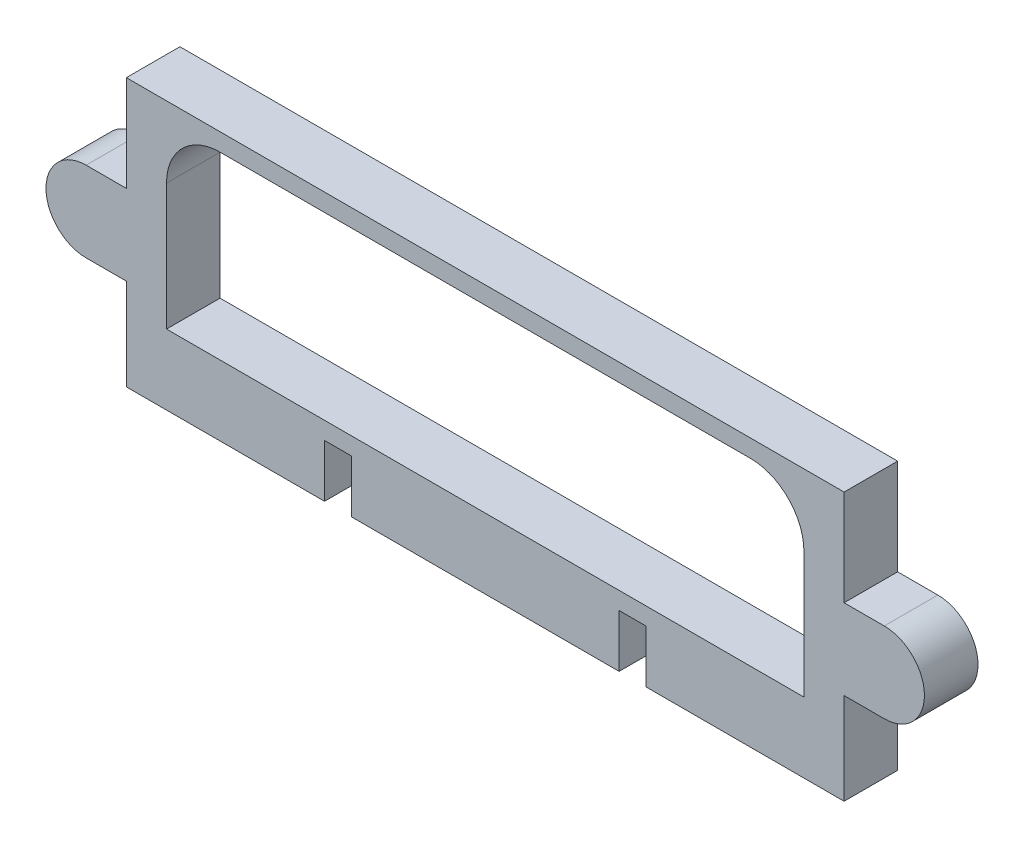
from build123d import *

# Parameters (mm, degrees)
SALIENTE_EXTRUIR1_DEPTH = 10


with BuildPart() as part:
    # Croquis1 → Saliente-Extruir1 (new body)
    with BuildSketch(Plane.XY):
        with BuildLine():
            Line((-25, 9.844348503), (-25, 0))
            Line((-25, 0), (25, 0))
            Line((25, 0), (25, 9.844348503))
            Line((25, 9.844348503), (30, 9.844348503))
            Line((30, 9.844348503), (30, 0))
            Line((30, 0), (67, 0))
            Line((67, 0), (67, 17.097567982))
            Line((67, 17.097567982), (74.5, 17.097567982))
            ThreePointArc((74.5, 17.097567982), (82, 24.597567982), (74.5, 32.097567982))
            Line((74.5, 32.097567982), (67, 32.097567982))
            Line((67, 32.097567982), (67, 50))
            Line((67, 50), (-67, 50))
            Line((-67, 50), (-67, 32.097567982))
            Line((-67, 32.097567982), (-74.5, 32.097567982))
            ThreePointArc((-74.5, 32.097567982), (-82, 24.597567982), (-74.5, 17.097567982))
            Line((-74.5, 17.097567982), (-67, 17.097567982))
            Line((-67, 17.097567982), (-67, 0))
            Line((-67, 0), (-30, 0))
            Line((-30, 0), (-30, 9.844348503))
            Line((-30, 9.844348503), (-25, 9.844348503))
        make_face()
        with BuildLine():
            Line((59.5, 13.1), (-59.5, 13.1))
            Line((-59.5, 13.1), (-59.5, 17.097567982))
            Line((-59.5, 17.097567982), (-59.5, 32.097567982))
            Line((-59.5, 32.097567982), (-59.5, 36.7))
            ThreePointArc((-59.5, 36.7), (-56.571067812, 43.771067812), (-49.5, 46.7))
            Line((-49.5, 46.7), (44.1, 46.7))
            Line((44.1, 46.7), (49.5, 46.7))
            ThreePointArc((49.5, 46.7), (56.571067812, 43.771067812), (59.5, 36.7))
            Line((59.5, 36.7), (59.5, 13.1))
        make_face(mode=Mode.SUBTRACT)
    extrude(amount=SALIENTE_EXTRUIR1_DEPTH)


solid = part.part
